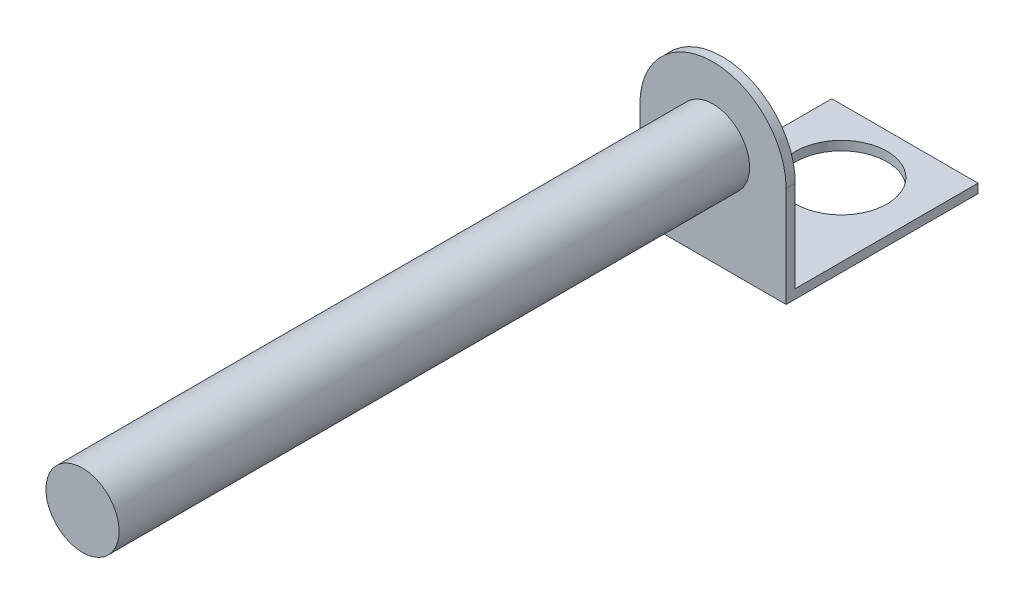
from build123d import *

# Parameters (mm, degrees)
SKETCH1_R           = 4
BOSS_EXTRUDE1_DEPTH = 69
BOSS_EXTRUDE2_DEPTH = 1
SKETCH3_W           = 16
SKETCH3_H           = 20
BOSS_EXTRUDE3_DEPTH = 1
SKETCH4_W           = 16
SKETCH4_H           = 1
BOSS_EXTRUDE4_DEPTH = 1
SKETCH5_R           = 5
CUT_EXTRUDE1_DEPTH  = 1


with BuildPart() as part:
    # Sketch1 → Boss-Extrude1 (new body)
    with BuildSketch(Plane.XY):
        Circle(SKETCH1_R)
    extrude(amount=BOSS_EXTRUDE1_DEPTH)

    # Sketch2 → Boss-Extrude2 (add)
    with BuildSketch(Plane(origin=(0, 0, 0), x_dir=(-1, 0, 0), z_dir=(0, 0, -1))):
        with BuildLine():
            Line((-8, 0), (-8, -10))
            Line((-8, -10), (8, -10))
            Line((8, -10), (8, 0))
            ThreePointArc((8, 0), (0, 8), (-8, 0))
        make_face()
    extrude(amount=BOSS_EXTRUDE2_DEPTH)



with BuildPart() as body_2:
    # Sketch3 → Boss-Extrude3 (new body)
    with BuildSketch(Plane.XZ.offset(10)):
        with Locations((0, -11)):
            Rectangle(SKETCH3_W, SKETCH3_H)
    extrude(amount=BOSS_EXTRUDE3_DEPTH)


with BuildPart() as part_1:
    add(part.part)

    add(body_2.part)  # Boss-Extrude4 merges body 2
    # Sketch4 → Boss-Extrude4 (add)
    with BuildSketch(Plane.XY.offset(-1)):
        with Locations((0, -10.5)):
            Rectangle(SKETCH4_W, SKETCH4_H)
    extrude(amount=BOSS_EXTRUDE4_DEPTH)

    # Sketch5 → Cut-Extrude1 (cut)
    with BuildSketch(Plane(origin=(0, -10, 0), x_dir=(1, 0, 0), z_dir=(0, 1, 0))):
        with Locations((0, 14.046188681)):
            Circle(SKETCH5_R)
    extrude(amount=-CUT_EXTRUDE1_DEPTH, mode=Mode.SUBTRACT)


solid = part_1.part
